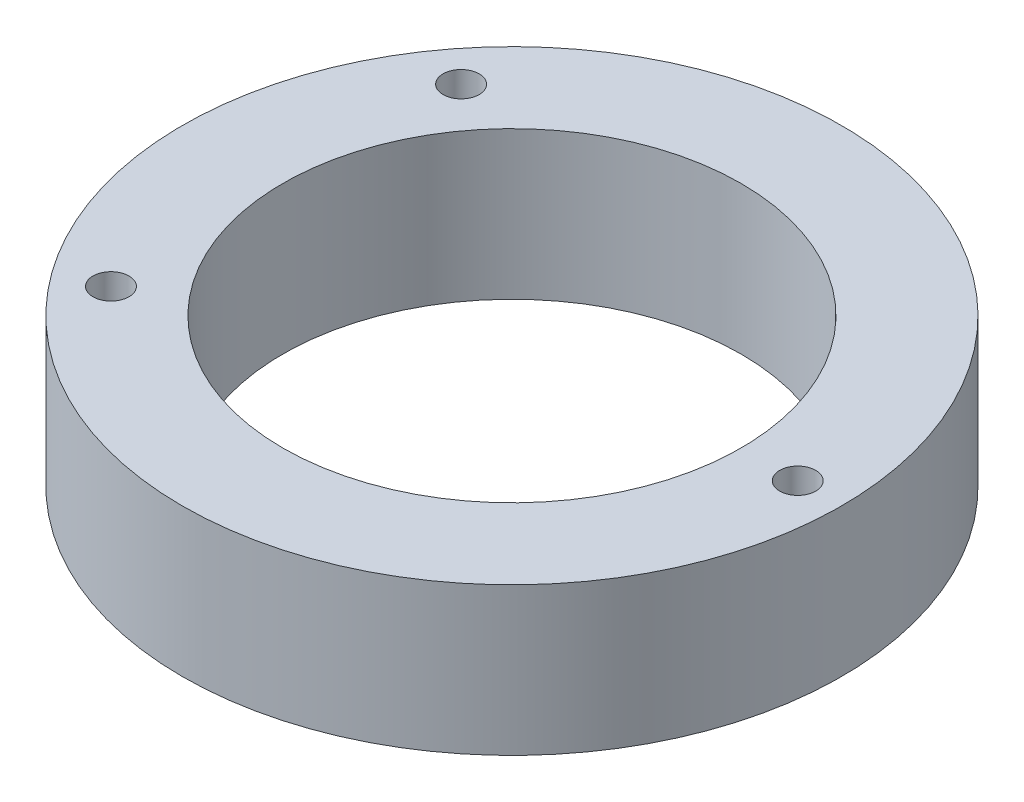
from build123d import *

# Parameters (mm, degrees)
SZKIC1_R                    = 32
SZKIC1_R_2                  = 22.25
SZKIC1_R_3                  = 1.75
DODANIE_WYCI_GNI_CIE1_DEPTH = 14.35


with BuildPart() as part:
    # Szkic1 → Dodanie-wyciągnięcie1 (new body)
    with BuildSketch(Plane(origin=(0, 0, 0), x_dir=(1, 0, 0), z_dir=(0, 1, 0))):
        Circle(SZKIC1_R)
        Circle(SZKIC1_R_2, mode=Mode.SUBTRACT)
        with Locations((27.75, 0)):
            Circle(SZKIC1_R_3, mode=Mode.SUBTRACT)
        with Locations((-21.932737229, -17.000515805)):
            Circle(SZKIC1_R_3, mode=Mode.SUBTRACT)
        with Locations((-21.932737229, 17.000515805)):
            Circle(SZKIC1_R_3, mode=Mode.SUBTRACT)
    extrude(amount=DODANIE_WYCI_GNI_CIE1_DEPTH)


solid = part.part
